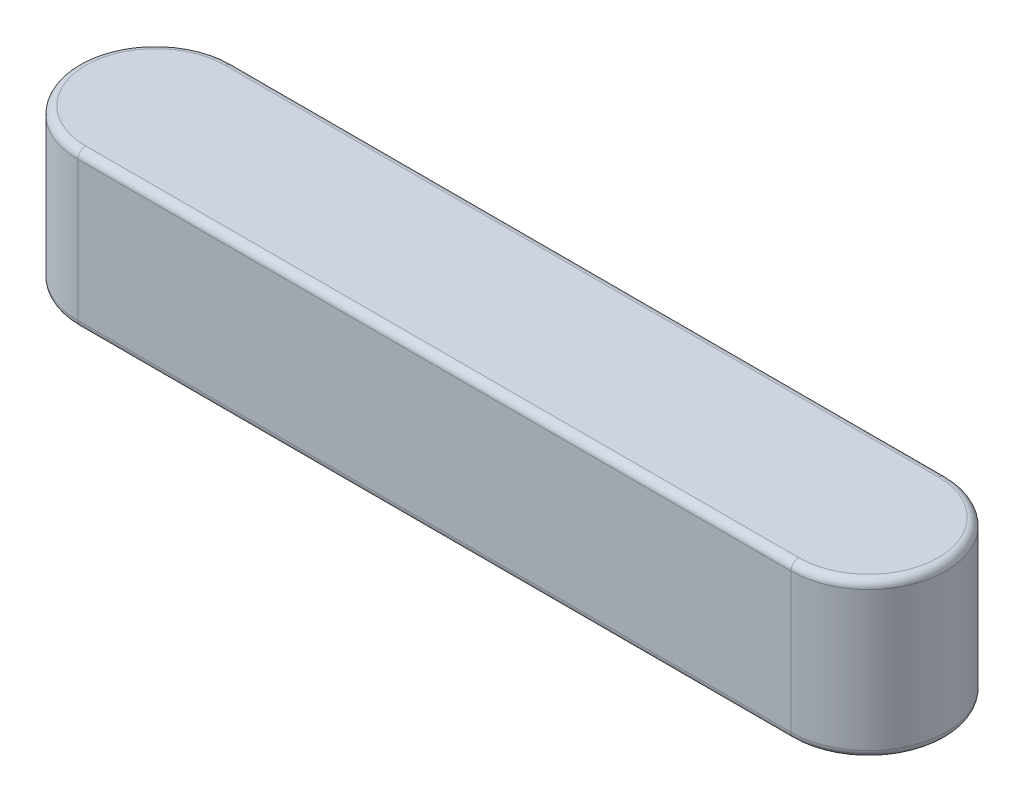
from build123d import *

# Parameters (mm, degrees)
EXTRUDE1_DEPTH = 5
FILLET1_R      = 0.25


with BuildPart() as part:
    # Sketch1 → Extrude1 (new body)
    with BuildSketch(Plane(origin=(0, 0, 0), x_dir=(1, 0, 0), z_dir=(0, 1, 0))):
        with BuildLine():
            Line((-23, 2.5), (0, 2.5))
            ThreePointArc((0, 2.5), (2.5, 0), (0, -2.5))
            Line((0, -2.5), (-23, -2.5))
            ThreePointArc((-23, -2.5), (-25.5, 0), (-23, 2.5))
        make_face()
    extrude(amount=EXTRUDE1_DEPTH)

    # Fillet1
    fillet1_edges = [part.edges().sort_by_distance(p)[0] for p in [
        (2.5, 5, 0),
        (-11.5, 5, -2.5),
        (-25.5, 5, 0),
        (-11.5, 0, -2.5),
        (2.5, 0, 0),
        (-11.5, 0, 2.5),
        (-25.5, 0, 0),
        (-11.5, 5, 2.5),
    ]]
    fillet(fillet1_edges, radius=FILLET1_R)


solid = part.part
